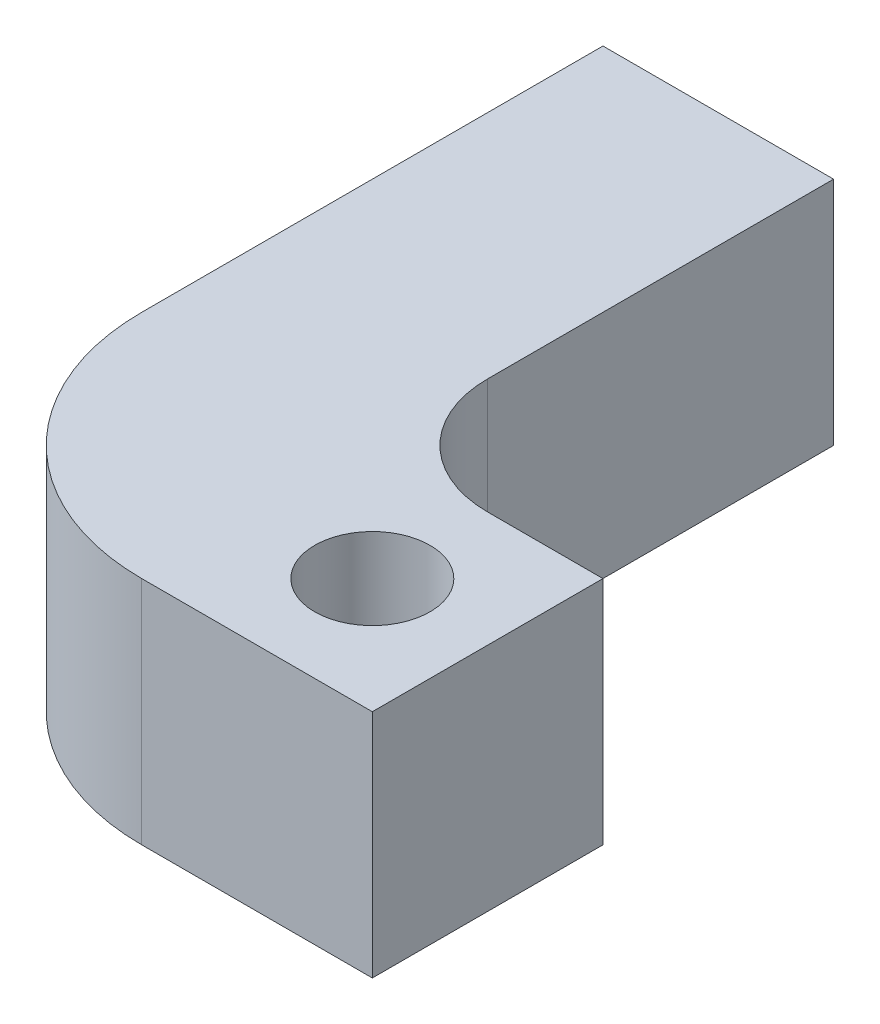
from build123d import *
from OCP.BRepFilletAPI import BRepFilletAPI_MakeFillet

# Parameters (mm, degrees)
BOSS_EXTRUDE1_DEPTH = 10
FILLET1_R1          = 5
FILLET1_R2          = 10
SKETCH3_R           = 2.5
CUT_EXTRUDE1_DEPTH  = 38.416573868


with BuildPart() as part:
    # Sketch2 → Boss-Extrude1 (new body)
    with BuildSketch(Plane(origin=(0, 0, 0), x_dir=(1, 0, 0), z_dir=(0, 1, 0))):
        Polygon((10, 0), (0, 0), (0, -30), (5, -30), (20, -30), (20, -20), (10, -20), align=None)
    extrude(amount=BOSS_EXTRUDE1_DEPTH)

    # Fillet1: one fillet with a radius per group of edges: ONE call of the kernel's fillet builder (fillet() takes one radius for all edges)
    fillet1_edges_1 = [part.edges().sort_by_distance(p)[0] for p in [
        (10, 5, 20),
    ]]
    fillet1_edges_2 = [part.edges().sort_by_distance(p)[0] for p in [
        (0, 5, 30),
    ]]
    fillet1 = BRepFilletAPI_MakeFillet(part.part.solid().wrapped)
    for e in fillet1_edges_1:
        fillet1.Add(FILLET1_R1, e.wrapped)
    for e in fillet1_edges_2:
        fillet1.Add(FILLET1_R2, e.wrapped)
    add(Compound.cast(fillet1.Shape()), mode=Mode.REPLACE)

    # Sketch3 → Cut-Extrude1 (cut, through all)
    with BuildSketch(Plane(origin=(0, 10, 0), x_dir=(1, 0, 0), z_dir=(0, 1, 0))):
        with Locations((15, -25)):
            Circle(SKETCH3_R)
    extrude(amount=-CUT_EXTRUDE1_DEPTH, mode=Mode.SUBTRACT)


solid = part.part
